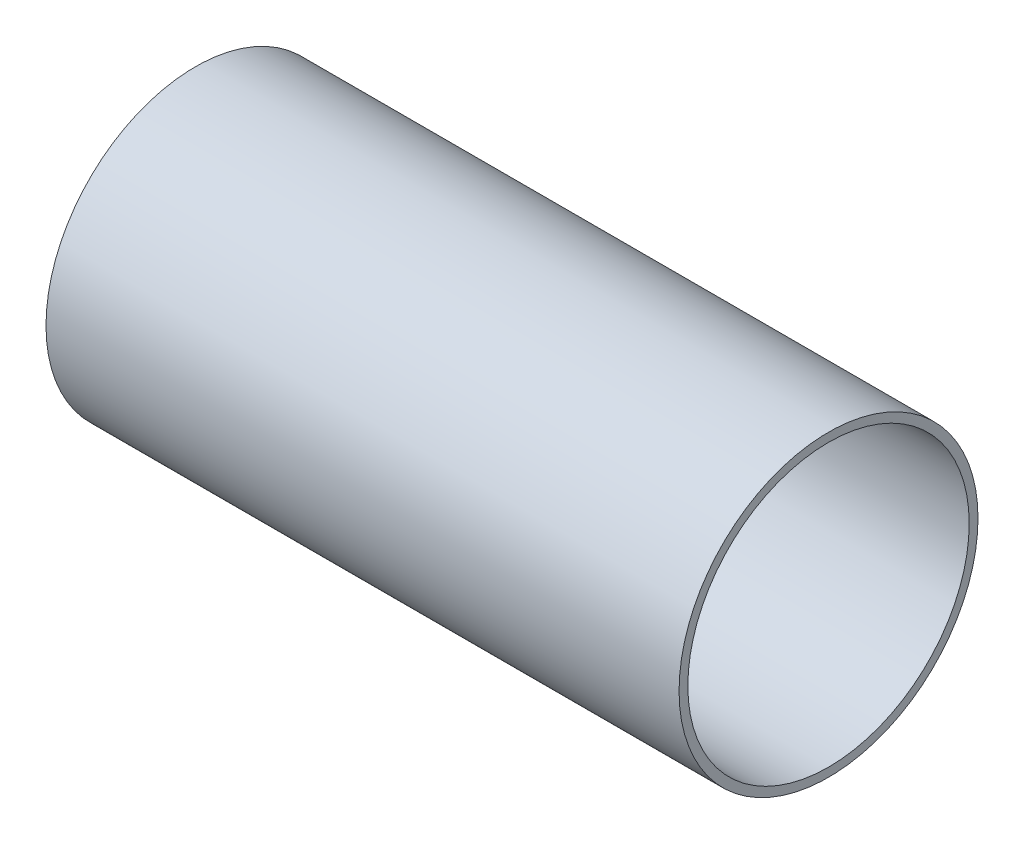
from build123d import *

# Parameters (mm, degrees)
SKETCH1_R           = 53.975
SKETCH1_R_2         = 50.8
BOSS_EXTRUDE1_DEPTH = 228.6


with BuildPart() as part:
    # Sketch1 → Boss-Extrude1 (new body)
    with BuildSketch(Plane(origin=(0, 0, 0), x_dir=(0, 0, -1), z_dir=(1, 0, 0))):
        Circle(SKETCH1_R)
        Circle(SKETCH1_R_2, mode=Mode.SUBTRACT)
    extrude(amount=BOSS_EXTRUDE1_DEPTH)


solid = part.part
